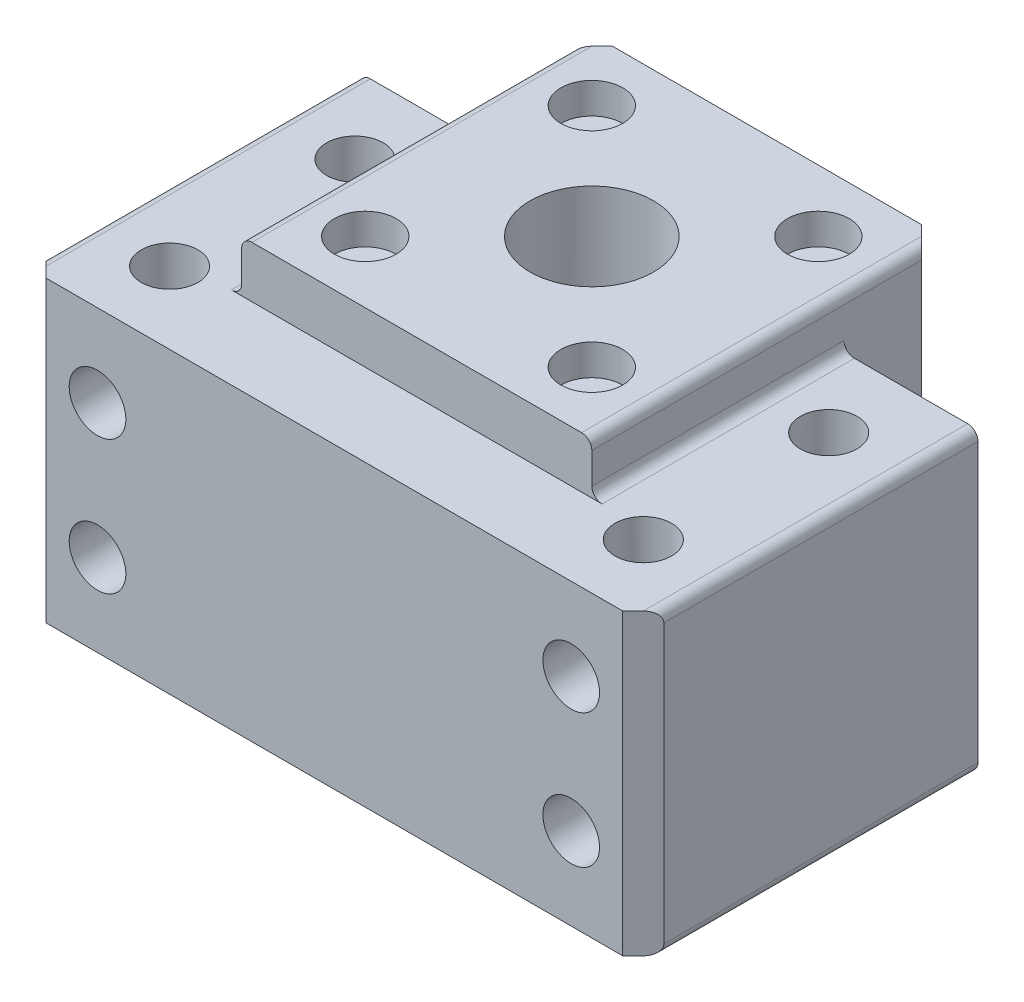
from build123d import *

# Parameters (mm, degrees)
SKETCH_1_W                  = 60
SKETCH_1_H                  = 32.5
SKETCH_1_R                  = 6
SKETCH_1_R_2                = 2.75
EXTRUDE_1_DEPTH             = 29
SKETCH_2_W                  = 34
SKETCH_2_H                  = 34
SKETCH_2_R                  = 6
EXTRUDE_2_DEPTH             = 34
SKETCH_3_R                  = 3
CUT_EXTRUDE_1_DEPTH         = 3
CHAMFER_1_SIZE              = 2
FILLET_1_R                  = 1
HOLE_WIZARD_M5_1_AT_2_COUNT = 2
HOLE_WIZARD_M5_1_AT_2_PITCH = 13
HOLE_WIZARD_M5_1_AT_3_COUNT = 2
HOLE_WIZARD_M5_1_AT_3_PITCH = 46
HOLE_WIZARD_M5_1_AT_4_COUNT = 2
HOLE_WIZARD_M5_1_AT_4_PITCH = 47.801673611


with BuildPart() as part:
    # 草图1 → 凸台-拉伸1 (new body)
    with BuildSketch(Plane(origin=(0, 0, 0), x_dir=(1, 0, 0), z_dir=(0, 1, 0))):
        Rectangle(SKETCH_1_W, SKETCH_1_H)
        with Locations((0, 8.75)):
            Circle(SKETCH_1_R, mode=Mode.SUBTRACT)
        with Locations((-23, 8.75)):
            Circle(SKETCH_1_R_2, mode=Mode.SUBTRACT)
        with Locations((-23, -9.25)):
            Circle(SKETCH_1_R_2, mode=Mode.SUBTRACT)
        with Locations((23, -9.25)):
            Circle(SKETCH_1_R_2, mode=Mode.SUBTRACT)
        with Locations((23, 8.75)):
            Circle(SKETCH_1_R_2, mode=Mode.SUBTRACT)
    extrude(amount=EXTRUDE_1_DEPTH)

    # 草图2 → 凸台-拉伸2 (add)
    with BuildSketch(Plane.XZ):
        with Locations((0, -8.75)):
            Rectangle(SKETCH_2_W, SKETCH_2_H)
        with Locations((0, -8.75)):
            Circle(SKETCH_2_R, mode=Mode.SUBTRACT)
    extrude(amount=-EXTRUDE_2_DEPTH)

    # 草图3 → 切除-拉伸1 (cut)
    with BuildSketch(Plane(origin=(0, 34, 0), x_dir=(1, 0, 0), z_dir=(0, 1, 0))):
        with Locations((-11, 19.75)):
            Circle(SKETCH_3_R)
        with Locations((11, 19.75)):
            Circle(SKETCH_3_R)
        with Locations((-11, -2.25)):
            Circle(SKETCH_3_R)
        with Locations((11, -2.25)):
            Circle(SKETCH_3_R)
    extrude(amount=-CUT_EXTRUDE_1_DEPTH, mode=Mode.SUBTRACT)

    # 倒角1
    chamfer_1_edges = [part.edges().sort_by_distance(p)[0] for p in [
        (-17, 17, -25.75),
        (17, 17, -25.75),
        (30, 14.5, 16.25),
        (-30, 14.5, 16.25),
    ]]
    chamfer(chamfer_1_edges, length=CHAMFER_1_SIZE)

    # 圆角1
    fillet_1_edges = [part.edges().sort_by_distance(p)[0] for p in [
        (-30, 29, -1),
        (-17, 0, -20),
        (-17, 29, -4),
        (-17, 34, -7.75),
        (17, 29, -4),
        (-30, 0, -1),
        (17, 0, -20),
        (30, 0, -1),
        (30, 29, -1),
        (17, 34, -7.75),
    ]]
    fillet(fillet_1_edges, radius=FILLET_1_R)

    # 草图7 → M5 六角头螺栓的柱形沉头孔1 (revolve, cut)
    with BuildSketch(Plane(origin=(-23, 8, -16.25), x_dir=(0, 1, 0), z_dir=(1, 0, 0))):
        Polygon((0, 0), (0, 32.5), (2.75, 32.5), (2.75, 0.5), (5.5, 0.5), (5.5, 0.025), (5.525, 0), align=None)
    hole_wizard_m5_1 = revolve(axis=Axis((-23, 8, -22.6), (0, 0, 1)), mode=Mode.SUBTRACT)

    # M5 六角头螺栓的柱形沉头孔1 at 2: M5 六角头螺栓的柱形沉头孔1 ×2
    with Locations(*[(0, i * HOLE_WIZARD_M5_1_AT_2_PITCH, 0) for i in range(1, HOLE_WIZARD_M5_1_AT_2_COUNT)]):
        add(hole_wizard_m5_1, mode=Mode.SUBTRACT)

    # M5 六角头螺栓的柱形沉头孔1 at 3: M5 六角头螺栓的柱形沉头孔1 ×2
    with Locations(*[(i * HOLE_WIZARD_M5_1_AT_3_PITCH, 0, 0) for i in range(1, HOLE_WIZARD_M5_1_AT_3_COUNT)]):
        add(hole_wizard_m5_1, mode=Mode.SUBTRACT)

    # M5 六角头螺栓的柱形沉头孔1 at 4: M5 六角头螺栓的柱形沉头孔1 ×2
    with Locations(*[Vector(0.962309403, 0.271957005, 0) * (i * HOLE_WIZARD_M5_1_AT_4_PITCH) for i in range(1, HOLE_WIZARD_M5_1_AT_4_COUNT)]):
        add(hole_wizard_m5_1, mode=Mode.SUBTRACT)


solid = part.part
